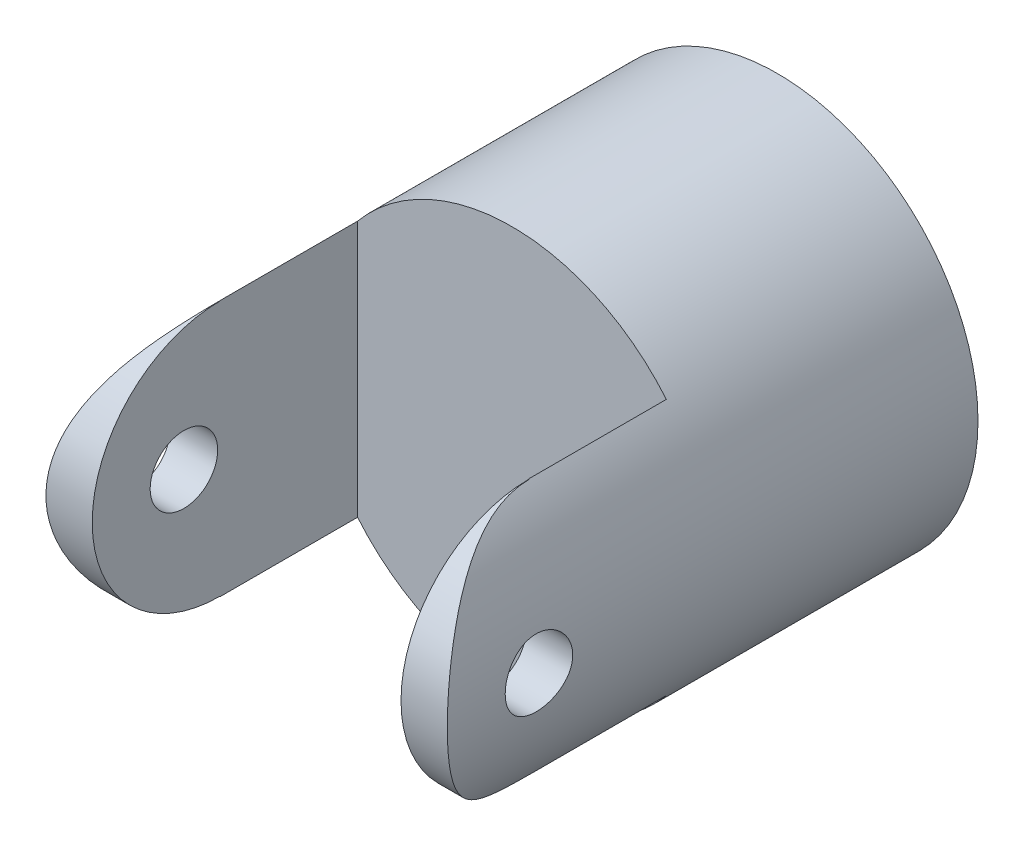
from build123d import *

# Parameters (mm, degrees)
SKETCH1_R           = 4.16
EXTRUDE1_DEPTH      = 11
SKETCH2_W           = 6.4
SKETCH2_H           = 6.357406019
EXTRUDE2_DEPTH      = 5.16
EXTRUDE2_DEPTH_BACK = 5.16
EXTRUDE3_DEPTH      = 5.16
EXTRUDE3_DEPTH_BACK = 5.16
SKETCH4_R           = 0.7
EXTRUDE4_DEPTH      = 5.1600001
EXTRUDE4_DEPTH_BACK = 5.1600001


with BuildPart() as part:
    # Sketch1 → Extrude1 (new body)
    with BuildSketch(Plane.XY):
        Circle(SKETCH1_R)
    extrude(amount=EXTRUDE1_DEPTH)

    # Sketch2 → Extrude2 (cut, two sides)
    with BuildSketch(Plane(origin=(0, 0, 0), x_dir=(1, 0, 0), z_dir=(0, 1, 0))) as extrude2_sk:
        with Locations((0, -8.67870301)):
            Rectangle(SKETCH2_W, SKETCH2_H)
    extrude(amount=EXTRUDE2_DEPTH, mode=Mode.SUBTRACT)
    extrude(extrude2_sk.sketch, amount=-EXTRUDE2_DEPTH_BACK, mode=Mode.SUBTRACT)

    # Sketch3 → Extrude3 (cut, two sides)
    with BuildSketch(Plane(origin=(0, 0, 0), x_dir=(0, 0, -1), z_dir=(1, 0, 0))) as extrude3_sk:
        with BuildLine():
            Line((-8.35, 2.65), (-8.35, 3.836721977))
            Line((-8.35, 3.836721977), (-12.822156105, 3.836721977))
            Line((-12.822156105, 3.836721977), (-12.822156105, -4.605164147))
            Line((-12.822156105, -4.605164147), (-8.35, -4.492230912))
            Line((-8.35, -4.492230912), (-8.35, -2.65))
            ThreePointArc((-8.35, -2.65), (-11, 0), (-8.35, 2.65))
        make_face()
    extrude(amount=EXTRUDE3_DEPTH, mode=Mode.SUBTRACT)
    extrude(extrude3_sk.sketch, amount=-EXTRUDE3_DEPTH_BACK, mode=Mode.SUBTRACT)

    # Sketch4 → Extrude4 (cut, two sides)
    with BuildSketch(Plane(origin=(0, 0, 0), x_dir=(0, 0, -1), z_dir=(1, 0, 0))) as extrude4_sk:
        with Locations((-9.1, 0)):
            Circle(SKETCH4_R)
    extrude(amount=EXTRUDE4_DEPTH, mode=Mode.SUBTRACT)
    extrude(extrude4_sk.sketch, amount=-EXTRUDE4_DEPTH_BACK, mode=Mode.SUBTRACT)


solid = part.part
